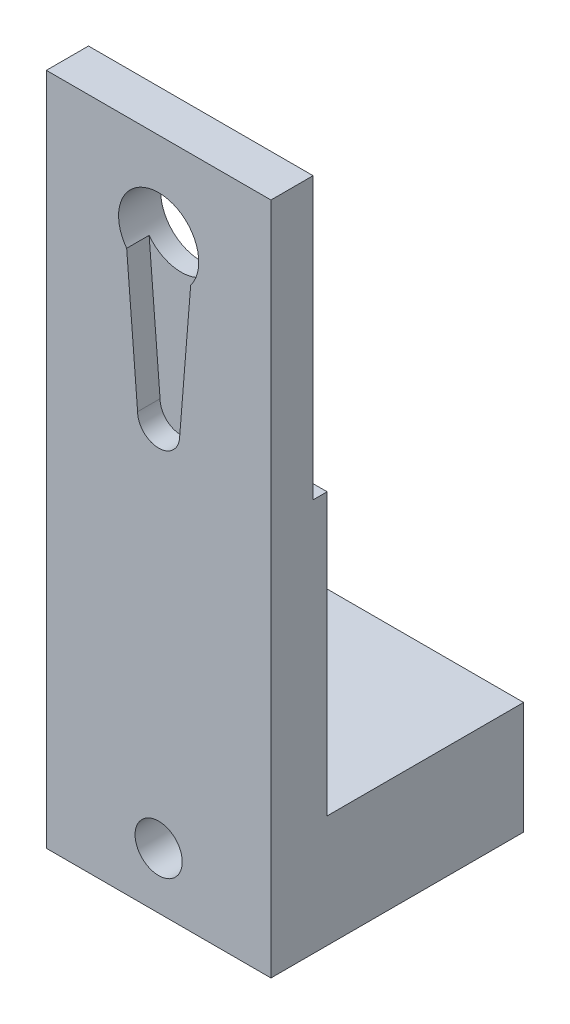
from build123d import *

# Parameters (mm, degrees)
SKETCH3_W           = 20
SKETCH3_H           = 60
BOSS_EXTRUDE3_DEPTH = 5
CUT_EXTRUDE2_DEPTH  = 2
SKETCH6_R           = 3.57
CUT_EXTRUDE3_DEPTH  = 3
SKETCH7_W           = 20
SKETCH7_H           = 10
BOSS_EXTRUDE4_DEPTH = 17.5
SKETCH8_R           = 2.1
CUT_EXTRUDE4_DEPTH  = 40
SKETCH9_W           = 1.25
SKETCH9_H           = 25
CUT_EXTRUDE5_DEPTH  = 30


with BuildPart() as part:
    # Sketch3 → Boss-Extrude3 (new body)
    with BuildSketch(Plane.XY):
        Rectangle(SKETCH3_W, SKETCH3_H)
    extrude(amount=BOSS_EXTRUDE3_DEPTH)

    # Sketch4 → Cut-Extrude2 (cut)
    with BuildSketch(Plane.XY.offset(5)):
        with BuildLine():
            Line((-2.85, 19.850023256), (-1.875, 7.739206809))
            Line((-1.875, 7.739206809), (1.875, 7.739206809))
            Line((1.875, 7.739206809), (2.85, 19.850023256))
            ThreePointArc((2.85, 19.850023256), (0, 18.43), (-2.85, 19.850023256))
        make_face()
        with BuildLine():
            Line((1.875, 7.739206809), (-1.875, 7.739206809))
            ThreePointArc((-1.875, 7.739206809), (0, 5.864206809), (1.875, 7.739206809))
        make_face()
        with BuildLine():
            ThreePointArc((3.57, 22), (-1.133666618, 25.385217866), (-2.85, 19.850023256))
            Line((-2.85, 19.850023256), (2.85, 19.850023256))
            ThreePointArc((2.85, 19.850023256), (3.385217866, 20.866333382), (3.57, 22))
        make_face()
        with BuildLine():
            Line((2.85, 19.850023256), (-2.85, 19.850023256))
            ThreePointArc((-2.85, 19.850023256), (0, 18.43), (2.85, 19.850023256))
        make_face()
    extrude(amount=-CUT_EXTRUDE2_DEPTH, mode=Mode.SUBTRACT)

    # Sketch6 → Cut-Extrude3 (cut)
    with BuildSketch(Plane.XY.offset(3)):
        with Locations((0, 22)):
            Circle(SKETCH6_R)
    extrude(amount=-CUT_EXTRUDE3_DEPTH, mode=Mode.SUBTRACT)

    # Sketch7 → Boss-Extrude4 (add)
    with BuildSketch(Plane(origin=(0, 0, 0), x_dir=(-1, 0, 0), z_dir=(0, 0, -1))):
        with Locations((0, -25)):
            Rectangle(SKETCH7_W, SKETCH7_H)
    extrude(amount=BOSS_EXTRUDE4_DEPTH)

    # Sketch8 → Cut-Extrude4 (cut)
    with BuildSketch(Plane(origin=(0, 0, -17.5), x_dir=(-1, 0, 0), z_dir=(0, 0, -1))):
        with Locations((0, -25)):
            Circle(SKETCH8_R)
    extrude(amount=-CUT_EXTRUDE4_DEPTH, mode=Mode.SUBTRACT)

    # Sketch9 → Cut-Extrude5 (cut)
    with BuildSketch(Plane(origin=(10, 0, 0), x_dir=(0, 0, -1), z_dir=(1, 0, 0))):
        with Locations((-0.625, 17.5)):
            Rectangle(SKETCH9_W, SKETCH9_H)
    extrude(amount=-CUT_EXTRUDE5_DEPTH, mode=Mode.SUBTRACT)


solid = part.part
